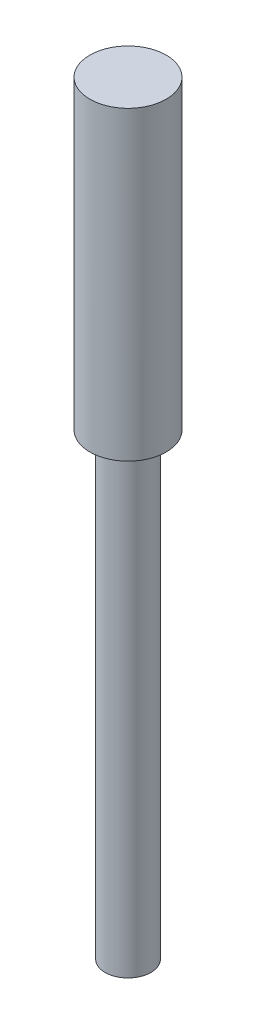
from build123d import *

# Parameters (mm, degrees)
SKETCH1_R           = 5
BOSS_EXTRUDE1_DEPTH = 100
SKETCH2_R           = 5
SKETCH2_R_2         = 3
CUT_EXTRUDE1_DEPTH  = 60


with BuildPart() as part:
    # Sketch1 → Boss-Extrude1 (new body)
    with BuildSketch(Plane(origin=(0, 0, 0), x_dir=(1, 0, 0), z_dir=(0, 1, 0))):
        Circle(SKETCH1_R)
    extrude(amount=BOSS_EXTRUDE1_DEPTH)

    # Sketch2 → Cut-Extrude1 (cut)
    with BuildSketch(Plane(origin=(0, 0, 0), x_dir=(-1, 0, 0), z_dir=(0, -1, 0))):
        Circle(SKETCH2_R)
        Circle(SKETCH2_R_2, mode=Mode.SUBTRACT)
    extrude(amount=-CUT_EXTRUDE1_DEPTH, mode=Mode.SUBTRACT)


solid = part.part
